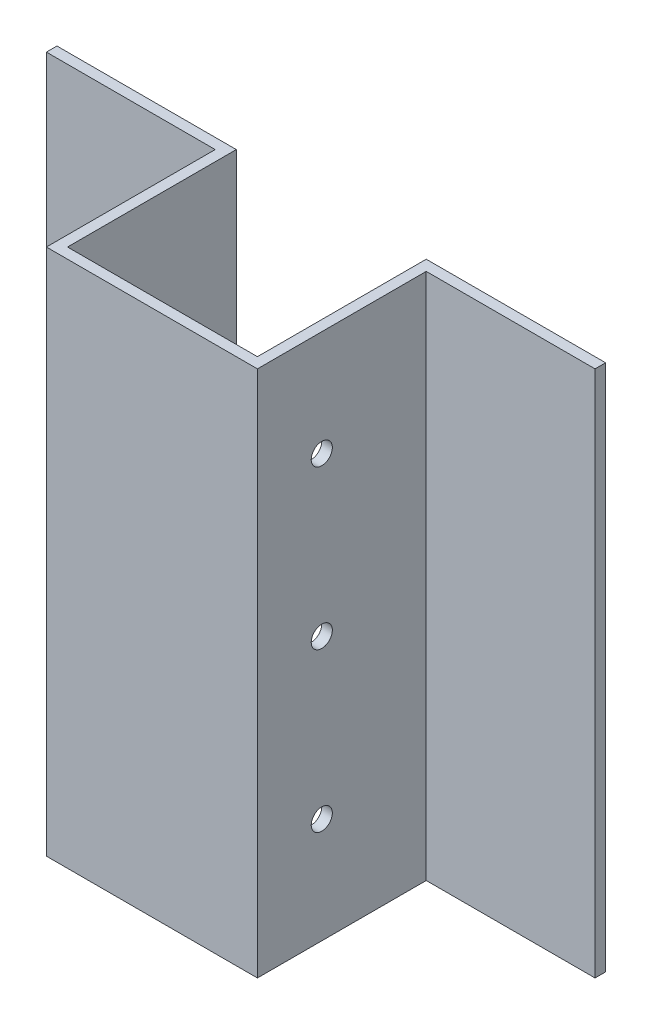
from build123d import *

# Parameters (mm, degrees)
ESQUISSE1_W             = 45
ESQUISSE1_H             = 250
BOSS_EXTRU_1_DEPTH      = 5
ESQUISSE2_W             = 80
ESQUISSE2_H             = 250
BOSS_EXTRU_2_DEPTH      = 5
ESQUISSE4_W             = 85
ESQUISSE4_H             = 250
BOSS_EXTRU_4_DEPTH      = 5
ESQUISSE5_R             = 5
ENL_V_MAT_EXTRU_1_DEPTH = 181


with BuildPart() as part:
    # Esquisse1 → Boss.-Extru.1 (new body)
    with BuildSketch(Plane.XY):
        with Locations((-22.5, 125)):
            Rectangle(ESQUISSE1_W, ESQUISSE1_H)
    boss_extru_1 = extrude(amount=BOSS_EXTRU_1_DEPTH)

    # Esquisse2 → Boss.-Extru.2 (add)
    with BuildSketch(Plane(origin=(0, 0, 0), x_dir=(0, 0, -1), z_dir=(1, 0, 0))):
        with Locations((35, 125)):
            Rectangle(ESQUISSE2_W, ESQUISSE2_H)
    boss_extru_2 = extrude(amount=BOSS_EXTRU_2_DEPTH)

    # Esquisse4 → Boss.-Extru.4 (add)
    with BuildSketch(Plane(origin=(0, 0, -75), x_dir=(-1, 0, 0), z_dir=(0, 0, -1))):
        with Locations((-42.5, 125)):
            Rectangle(ESQUISSE4_W, ESQUISSE4_H)
    boss_extru_4 = extrude(amount=BOSS_EXTRU_4_DEPTH)

    # Symétrie1: Boss.-Extru.1, Boss.-Extru.2, Boss.-Extru.4 across plane
    add(boss_extru_1.mirror(Plane(origin=(-45, 0, 5), x_dir=(0, 0, 1), z_dir=(1, 0, 0))))
    add(boss_extru_2.mirror(Plane(origin=(-45, 0, 5), x_dir=(0, 0, 1), z_dir=(1, 0, 0))))
    add(boss_extru_4.mirror(Plane(origin=(-45, 0, 5), x_dir=(0, 0, 1), z_dir=(1, 0, 0))))

    # Esquisse5 → Enlèv. mat.-Extru.1 (cut, through all)
    with BuildSketch(Plane(origin=(5, 0, 0), x_dir=(0, 0, -1), z_dir=(1, 0, 0))):
        with Locations((25.5, 125)):
            Circle(ESQUISSE5_R)
        with Locations((25.5, 200)):
            Circle(ESQUISSE5_R)
        with Locations((25.5, 50)):
            Circle(ESQUISSE5_R)
    extrude(amount=-ENL_V_MAT_EXTRU_1_DEPTH, mode=Mode.SUBTRACT)


solid = part.part
